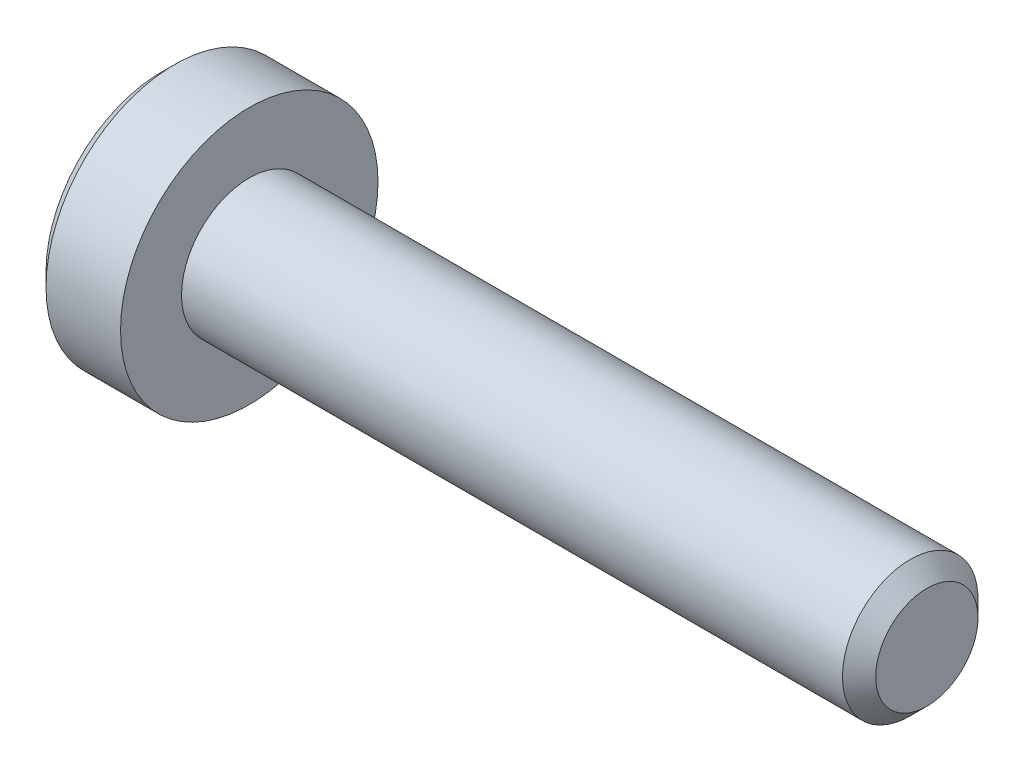
from build123d import *

# Parameters (mm, degrees)
CUT_EXTRUDE1_DEPTH = 0.7


with BuildPart() as part:
    # Sketch1 → Revolve1 (revolve)
    with BuildSketch(Plane.XY):
        Polygon((-1.3, 0), (-1.3, 1.7), (-1.1, 1.9), (0, 1.9), (0, 1), (9.7545, 1), (10, 0.7545), (10, 0), align=None)
    revolve(axis=Axis((10, 0, 0), (-1, 0, 0)))

    # Sketch2 → Cut-Extrude1 (cut)
    with BuildSketch(Plane(origin=(-1.3, 0, 0), x_dir=(0, 0, -1), z_dir=(1, 0, 0))):
        Polygon((-0.65, -0.375277675), (0, -0.75055535), (0.65, -0.375277675), (0.65, 0.375277675), (0, 0.75055535), (-0.65, 0.375277675), align=None)
    extrude(amount=CUT_EXTRUDE1_DEPTH, mode=Mode.SUBTRACT)


solid = part.part
